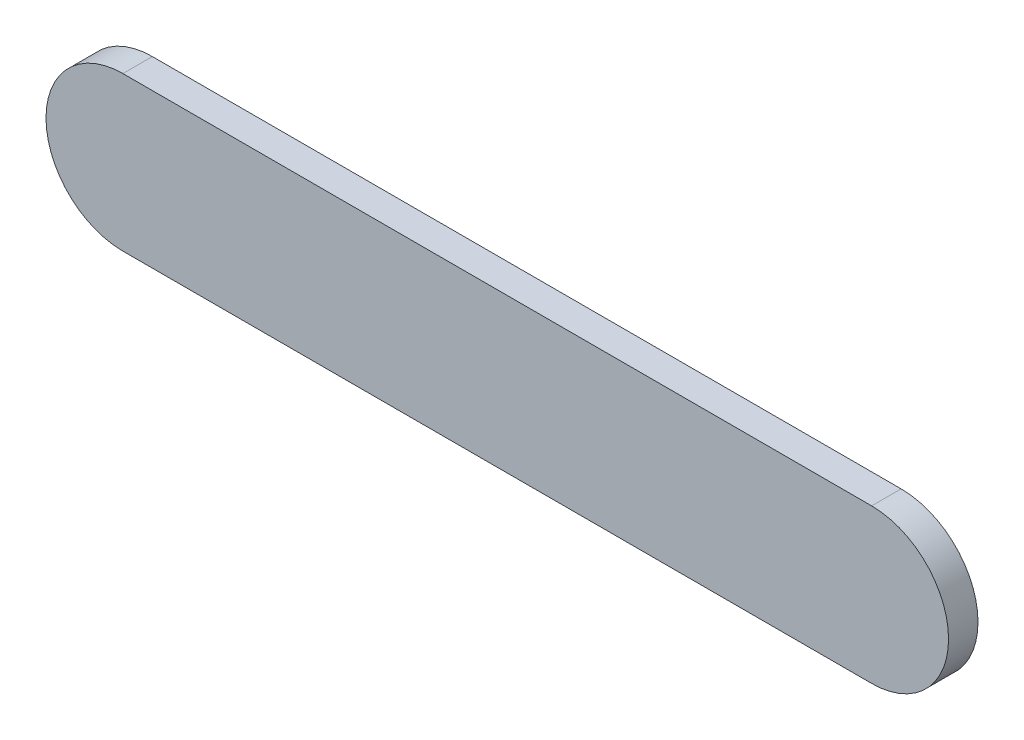
from build123d import *

# Parameters (mm, degrees)
SALIENTE_EXTRUIR1_DEPTH = 6


with BuildPart() as part:
    # Croquis1 → Saliente-Extruir1 (new body)
    with BuildSketch(Plane.XY):
        with BuildLine():
            Line((0, 15.66), (152.5, 15.66))
            ThreePointArc((152.5, 15.66), (168.16, 0), (152.5, -15.66))
            Line((152.5, -15.66), (0, -15.66))
            ThreePointArc((0, -15.66), (-15.66, 0), (0, 15.66))
        make_face()
    extrude(amount=SALIENTE_EXTRUIR1_DEPTH)


solid = part.part
